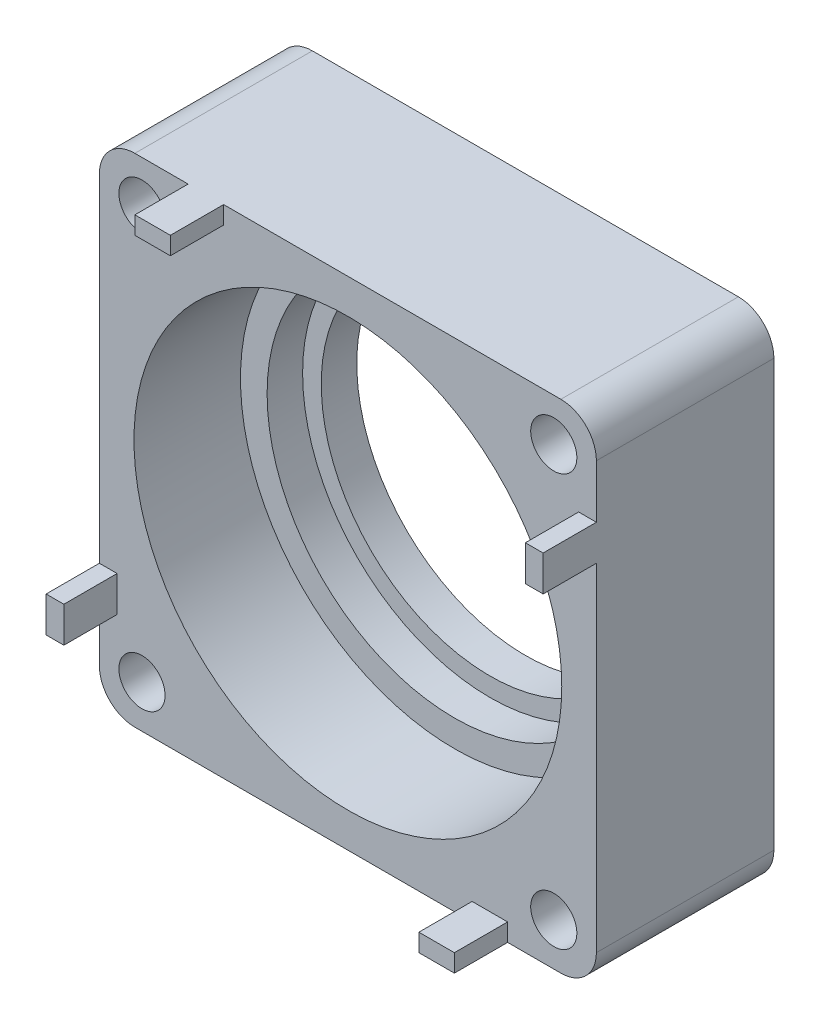
from build123d import *

# Parameters (mm, degrees)
SKETCH_1_W               = 28
SKETCH_1_H               = 28
EXTRUDE_1_DEPTH          = 10
SKETCH_2_R               = 9.5
CUT_EXTRUDE_1_DEPTH      = 11
SKETCH_3_R               = 10.55
CUT_EXTRUDE_2_DEPTH      = 8
SKETCH_4_R               = 12.05
CUT_EXTRUDE_3_DEPTH      = 6
FILLET_1_R               = 2
SKETCH_5_R               = 1.3
CUT_EXTRUDE_4_DEPTH      = 11
SKETCH_6_W               = 1
SKETCH_6_H               = 2
EXTRUDE_2_DEPTH          = 3
PATTERN_CIRCULAR_1_COUNT = 4


with BuildPart() as part:
    # 草图1 → 凸台-拉伸1 (new body)
    with BuildSketch(Plane.XY):
        Rectangle(SKETCH_1_W, SKETCH_1_H)
    extrude(amount=EXTRUDE_1_DEPTH)

    # 草图2 → 切除-拉伸1 (cut, through all)
    with BuildSketch(Plane.XY.offset(10)):
        Circle(SKETCH_2_R)
    extrude(amount=-CUT_EXTRUDE_1_DEPTH, mode=Mode.SUBTRACT)

    # 草图3 → 切除-拉伸2 (cut)
    with BuildSketch(Plane.XY.offset(10)):
        Circle(SKETCH_3_R)
    extrude(amount=-CUT_EXTRUDE_2_DEPTH, mode=Mode.SUBTRACT)

    # 草图4 → 切除-拉伸3 (cut)
    with BuildSketch(Plane.XY.offset(10)):
        Circle(SKETCH_4_R)
    extrude(amount=-CUT_EXTRUDE_3_DEPTH, mode=Mode.SUBTRACT)

    # 圆角1
    fillet_1_edges = [part.edges().sort_by_distance(p)[0] for p in [
        (14, -14, 5),
        (-14, -14, 5),
        (-14, 14, 5),
        (14, 14, 5),
    ]]
    fillet(fillet_1_edges, radius=FILLET_1_R)

    # 草图5 → 切除-拉伸4 (cut, through all)
    with BuildSketch(Plane.XY.offset(10)):
        with Locations((-11.6, 11.6)):
            Circle(SKETCH_5_R)
        with Locations((11.6, 11.6)):
            Circle(SKETCH_5_R)
        with Locations((11.6, -11.6)):
            Circle(SKETCH_5_R)
        with Locations((-11.6, -11.6)):
            Circle(SKETCH_5_R)
    extrude(amount=-CUT_EXTRUDE_4_DEPTH, mode=Mode.SUBTRACT)

    # 草图6 → 凸台-拉伸2 (add)
    with BuildSketch(Plane.XY.offset(10)):
        with Locations((-13.5, -8)):
            Rectangle(SKETCH_6_W, SKETCH_6_H)
    extrude_2 = extrude(amount=EXTRUDE_2_DEPTH)

    # 阵列(圆周)1: 凸台-拉伸2 ×4 about axis
    pattern_circular_1_axis = Axis((0, 0, 0), (0, 0, 1))
    for i in range(1, PATTERN_CIRCULAR_1_COUNT):
        add(extrude_2.rotate(pattern_circular_1_axis, i * 360 / PATTERN_CIRCULAR_1_COUNT))


solid = part.part
